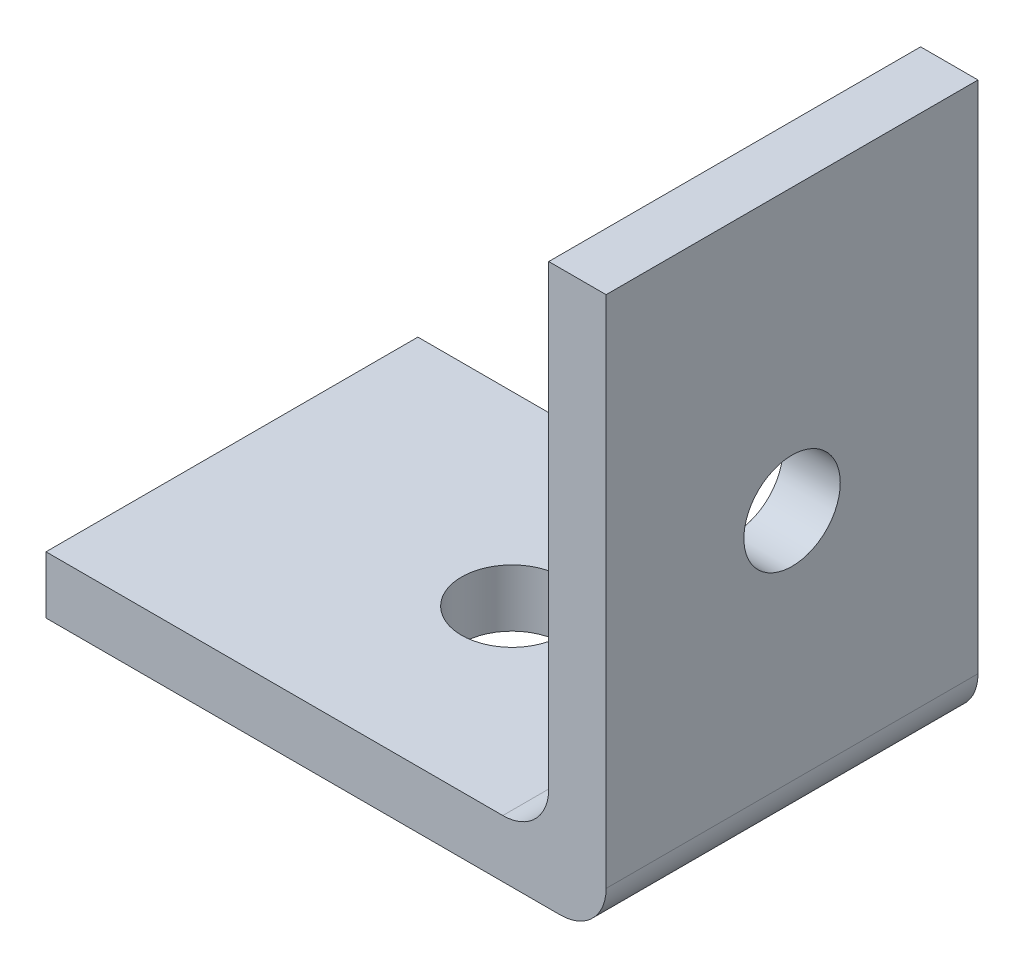
from build123d import *

# Parameters (mm, degrees)
BOSS_EXTRUDE1_DEPTH = 20.574
FILLET1_R           = 2.54
FILLET2_R           = 2.54
SKETCH2_R           = 2.667
CUT_EXTRUDE1_DEPTH  = 31.988
SKETCH3_R           = 2.794
CUT_EXTRUDE2_DEPTH  = 31.988


with BuildPart() as part:
    # Sketch1 → Boss-Extrude1 (new body)
    with BuildSketch(Plane.XY):
        Polygon((12.319, 1.5875), (12.319, 29.4005), (15.494, 29.4005), (15.494, -1.5875), (-15.494, -1.5875), (-15.494, 1.5875), align=None)
    extrude(amount=BOSS_EXTRUDE1_DEPTH)

    # Fillet1
    fillet1_edges = [part.edges().sort_by_distance(p)[0] for p in [
        (12.319, 1.5875, 10.287),
    ]]
    fillet(fillet1_edges, radius=FILLET1_R)

    # Fillet2
    fillet2_edges = [part.edges().sort_by_distance(p)[0] for p in [
        (15.494, -1.5875, 10.287),
    ]]
    fillet(fillet2_edges, radius=FILLET2_R)

    # Sketch2 → Cut-Extrude1 (cut, through all)
    with BuildSketch(Plane(origin=(15.494, 0, 0), x_dir=(0, 0, -1), z_dir=(1, 0, 0))):
        with Locations((-10.287, 13.9065)):
            Circle(SKETCH2_R)
    extrude(amount=-CUT_EXTRUDE1_DEPTH, mode=Mode.SUBTRACT)

    # Sketch3 → Cut-Extrude2 (cut, through all)
    with BuildSketch(Plane.XZ.offset(1.5875)):
        with Locations((0, 10.287)):
            Circle(SKETCH3_R)
    extrude(amount=-CUT_EXTRUDE2_DEPTH, mode=Mode.SUBTRACT)


solid = part.part
